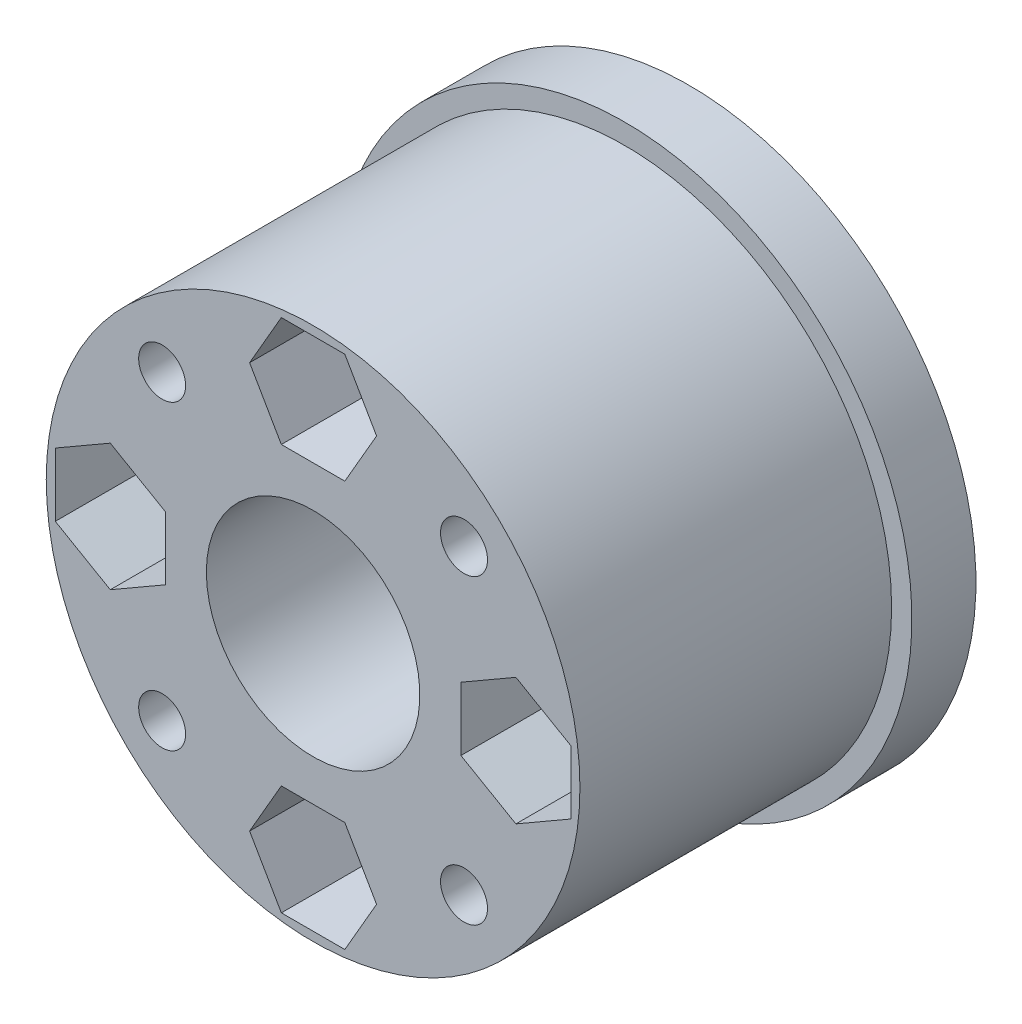
from build123d import *

# Parameters (mm, degrees)
ATTACHMENTBOLTHOLES_START = -4
SKETCH11_R                = 1.325
ATTACHMENTBOLTHOLES_DEPTH = 19.6
SKETCH13_R                = 1.975
SHAFTBOLTHEAD_DEPTH       = 2.2
SHAFTBOLTTHRU_START       = -4
SKETCH14_R                = 1.1
SHAFTBOLTTHRU_DEPTH       = 19.6
NUTHOLE_DEPTH             = 12.6
CIRPATTERN1_COUNT         = 4


with BuildPart() as part:
    # Sketch10 → Revolve1 (revolve)
    with BuildSketch(Plane(origin=(0, 0, 0), x_dir=(1, 0, 0), z_dir=(0, 1, 0))):
        Polygon((-13.45, 3), (-7.5, 3), (-7.5, 2), (-5, 2), (-5, -14.6), (-12.5, -14.6), (-12.5, 0), (-13.45, 0), align=None)
    revolve(axis=Axis((0, 0, -38.468953364), (0, 0, 1)))

    # Sketch11 → AttachmentBoltHoles (cut)
    with BuildSketch(Plane.XY.offset(ATTACHMENTBOLTHOLES_START)):
        with Locations((9.5, 0)):
            Circle(SKETCH11_R)
    attachmentboltholes = extrude(amount=ATTACHMENTBOLTHOLES_DEPTH, mode=Mode.SUBTRACT)

    # Sketch13 → ShaftBoltHead (cut)
    with BuildSketch(Plane(origin=(0, 0, -3), x_dir=(-1, 0, 0), z_dir=(0, 0, -1))):
        with Locations((-7.071067812, 7.071067812)):
            Circle(SKETCH13_R)
    shaftbolthead = extrude(amount=-SHAFTBOLTHEAD_DEPTH, mode=Mode.SUBTRACT)

    # Sketch14 → ShaftBoltThru (cut)
    with BuildSketch(Plane.XY.offset(SHAFTBOLTTHRU_START)):
        with Locations((7.071067812, 7.071067812)):
            Circle(SKETCH14_R)
    shaftboltthru = extrude(amount=SHAFTBOLTTHRU_DEPTH, mode=Mode.SUBTRACT)

    # Sketch12 → NutHole (cut)
    with BuildSketch(Plane.XY.offset(14.6)):
        Polygon((12.075, -1.486676943), (12.075, 1.486676943), (9.5, 2.973353886), (6.925, 1.486676943), (6.925, -1.486676943), (9.5, -2.973353886), align=None)
    nuthole = extrude(amount=-NUTHOLE_DEPTH, mode=Mode.SUBTRACT)

    # CirPattern1: AttachmentBoltHoles, ShaftBoltHead, ShaftBoltThru, NutHole ×4 about axis
    cirpattern1_axis = Axis((0, 0, 0), (0, 0, 1))
    for i in range(1, CIRPATTERN1_COUNT):
        add(attachmentboltholes.rotate(cirpattern1_axis, i * 360 / CIRPATTERN1_COUNT), mode=Mode.SUBTRACT)
        add(shaftbolthead.rotate(cirpattern1_axis, i * 360 / CIRPATTERN1_COUNT), mode=Mode.SUBTRACT)
        add(shaftboltthru.rotate(cirpattern1_axis, i * 360 / CIRPATTERN1_COUNT), mode=Mode.SUBTRACT)
        add(nuthole.rotate(cirpattern1_axis, i * 360 / CIRPATTERN1_COUNT), mode=Mode.SUBTRACT)


solid = part.part
